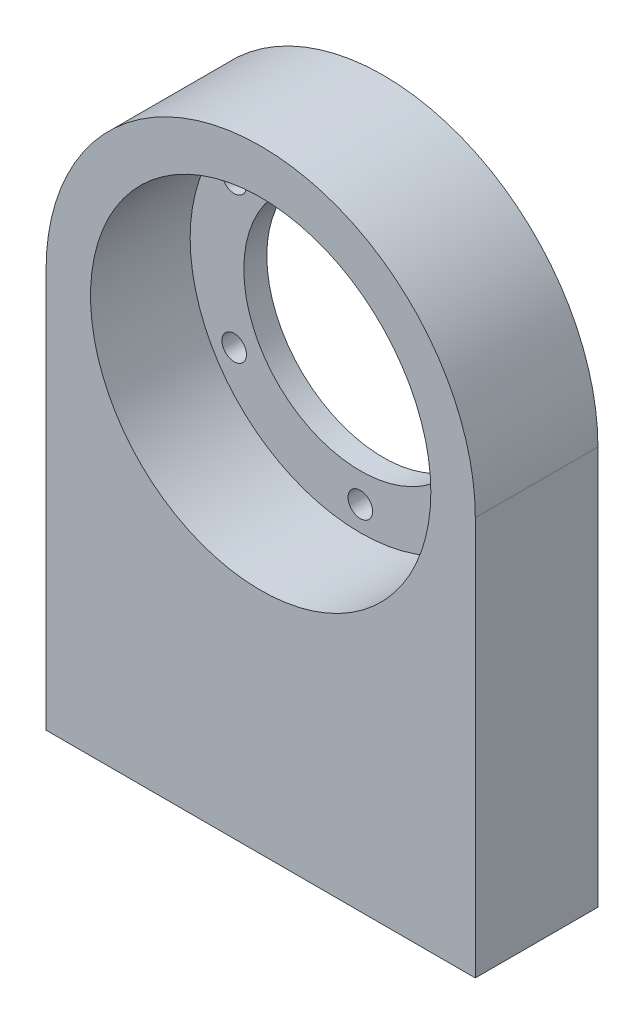
from build123d import *

# Parameters (mm, degrees)
ESQUISSE1_R             = 7.6
BOSS_EXTRU_1_DEPTH      = 8
ESQUISSE2_R             = 11.1
ENL_V_MAT_EXTRU_1_DEPTH = 6.5
ENL_V_MAT_EXTRU_2_REACH = 10
ESQUISSE3_R             = 0.8
ESQUISSE4_R             = 1.5
ENL_V_MAT_EXTRU_3_DEPTH = 15


with BuildPart() as part:
    # Esquisse1 → Boss.-Extru.1 (new body)
    with BuildSketch(Plane.XY):
        with BuildLine():
            Line((-14, 0), (-14, -26))
            Line((-14, -26), (14, -26))
            Line((14, -26), (14, 0))
            ThreePointArc((14, 0), (0, 14), (-14, 0))
        make_face()
        Circle(ESQUISSE1_R, mode=Mode.SUBTRACT)
    extrude(amount=BOSS_EXTRU_1_DEPTH)

    # Esquisse2 → Enlèv. mat.-Extru.1 (cut)
    with BuildSketch(Plane.XY.offset(8)):
        Circle(ESQUISSE2_R)
    extrude(amount=-ENL_V_MAT_EXTRU_1_DEPTH, mode=Mode.SUBTRACT)

    # Esquisse3 → Enlèv. mat.-Extru.2 (cut, up to next)
    with BuildSketch(Plane(origin=(0, 0, 0), x_dir=(-1, 0, 0), z_dir=(0, 0, -1)), mode=Mode.PRIVATE) as enl_v_mat_extru_2_sk1:
        with Locations((0, 9.5)):
            Circle(ESQUISSE3_R)
    enl_v_mat_extru_2_tool1 = extrude(enl_v_mat_extru_2_sk1.sketch, amount=-ENL_V_MAT_EXTRU_2_REACH, mode=Mode.PRIVATE) & part.part
    add(enl_v_mat_extru_2_tool1.solids().sort_by_distance((0, 9.5, 0))[0], mode=Mode.SUBTRACT)
    # Esquisse3 → Enlèv. mat.-Extru.2 (cut, up to next)
    with BuildSketch(Plane(origin=(0, 0, 0), x_dir=(-1, 0, 0), z_dir=(0, 0, -1)), mode=Mode.PRIVATE) as enl_v_mat_extru_2_sk2:
        with Locations((8.227241336, 4.75)):
            Circle(ESQUISSE3_R)
    enl_v_mat_extru_2_tool2 = extrude(enl_v_mat_extru_2_sk2.sketch, amount=-ENL_V_MAT_EXTRU_2_REACH, mode=Mode.PRIVATE) & part.part
    add(enl_v_mat_extru_2_tool2.solids().sort_by_distance((-8.227241, 4.75, 0))[0], mode=Mode.SUBTRACT)
    # Esquisse3 → Enlèv. mat.-Extru.2 (cut, up to next)
    with BuildSketch(Plane(origin=(0, 0, 0), x_dir=(-1, 0, 0), z_dir=(0, 0, -1)), mode=Mode.PRIVATE) as enl_v_mat_extru_2_sk3:
        with Locations((8.227241336, -4.75)):
            Circle(ESQUISSE3_R)
    enl_v_mat_extru_2_tool3 = extrude(enl_v_mat_extru_2_sk3.sketch, amount=-ENL_V_MAT_EXTRU_2_REACH, mode=Mode.PRIVATE) & part.part
    add(enl_v_mat_extru_2_tool3.solids().sort_by_distance((-8.227241, -4.75, 0))[0], mode=Mode.SUBTRACT)
    # Esquisse3 → Enlèv. mat.-Extru.2 (cut, up to next)
    with BuildSketch(Plane(origin=(0, 0, 0), x_dir=(-1, 0, 0), z_dir=(0, 0, -1)), mode=Mode.PRIVATE) as enl_v_mat_extru_2_sk4:
        with Locations((0, -9.5)):
            Circle(ESQUISSE3_R)
    enl_v_mat_extru_2_tool4 = extrude(enl_v_mat_extru_2_sk4.sketch, amount=-ENL_V_MAT_EXTRU_2_REACH, mode=Mode.PRIVATE) & part.part
    add(enl_v_mat_extru_2_tool4.solids().sort_by_distance((0, -9.5, 0))[0], mode=Mode.SUBTRACT)
    # Esquisse3 → Enlèv. mat.-Extru.2 (cut, up to next)
    with BuildSketch(Plane(origin=(0, 0, 0), x_dir=(-1, 0, 0), z_dir=(0, 0, -1)), mode=Mode.PRIVATE) as enl_v_mat_extru_2_sk5:
        with Locations((-8.227241336, -4.75)):
            Circle(ESQUISSE3_R)
    enl_v_mat_extru_2_tool5 = extrude(enl_v_mat_extru_2_sk5.sketch, amount=-ENL_V_MAT_EXTRU_2_REACH, mode=Mode.PRIVATE) & part.part
    add(enl_v_mat_extru_2_tool5.solids().sort_by_distance((8.227241, -4.75, 0))[0], mode=Mode.SUBTRACT)
    # Esquisse3 → Enlèv. mat.-Extru.2 (cut, up to next)
    with BuildSketch(Plane(origin=(0, 0, 0), x_dir=(-1, 0, 0), z_dir=(0, 0, -1)), mode=Mode.PRIVATE) as enl_v_mat_extru_2_sk6:
        with Locations((-8.227241336, 4.75)):
            Circle(ESQUISSE3_R)
    enl_v_mat_extru_2_tool6 = extrude(enl_v_mat_extru_2_sk6.sketch, amount=-ENL_V_MAT_EXTRU_2_REACH, mode=Mode.PRIVATE) & part.part
    add(enl_v_mat_extru_2_tool6.solids().sort_by_distance((8.227241, 4.75, 0))[0], mode=Mode.SUBTRACT)

    # Esquisse4 → Enlèv. mat.-Extru.3 (cut)
    with BuildSketch(Plane.XZ.offset(26)):
        with Locations((-10, 4)):
            Circle(ESQUISSE4_R)
        with Locations((10, 4)):
            Circle(ESQUISSE4_R)
    extrude(amount=-ENL_V_MAT_EXTRU_3_DEPTH, mode=Mode.SUBTRACT)


solid = part.part
